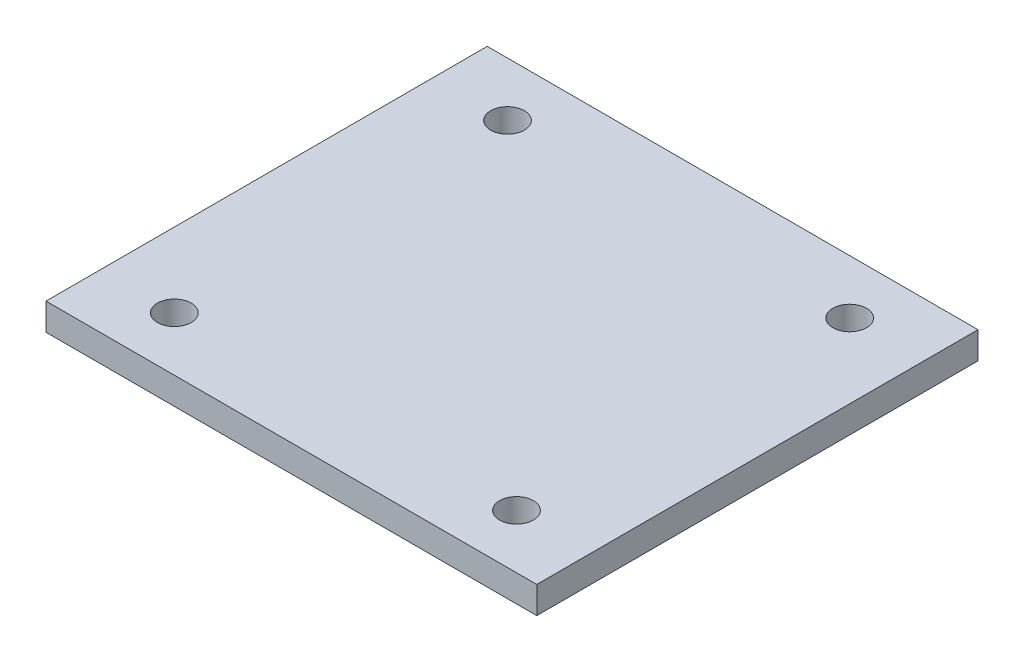
from build123d import *

# Parameters (mm, degrees)
ESQUISSE1_W        = 109
ESQUISSE1_H        = 98
ESQUISSE1_R        = 3.75
BOSS_EXTRU_1_DEPTH = 6


with BuildPart() as part:
    # Esquisse1 → Boss.-Extru.1 (new body)
    with BuildSketch(Plane(origin=(0, 0, 0), x_dir=(1, 0, 0), z_dir=(0, 1, 0))):
        with Locations((54.5, 49)):
            Rectangle(ESQUISSE1_W, ESQUISSE1_H)
        with Locations((16.5, 86)):
            Circle(ESQUISSE1_R, mode=Mode.SUBTRACT)
        with Locations((92.5, 86)):
            Circle(ESQUISSE1_R, mode=Mode.SUBTRACT)
        with Locations((92.5, 12)):
            Circle(ESQUISSE1_R, mode=Mode.SUBTRACT)
        with Locations((16.5, 12)):
            Circle(ESQUISSE1_R, mode=Mode.SUBTRACT)
    extrude(amount=BOSS_EXTRU_1_DEPTH)


solid = part.part
